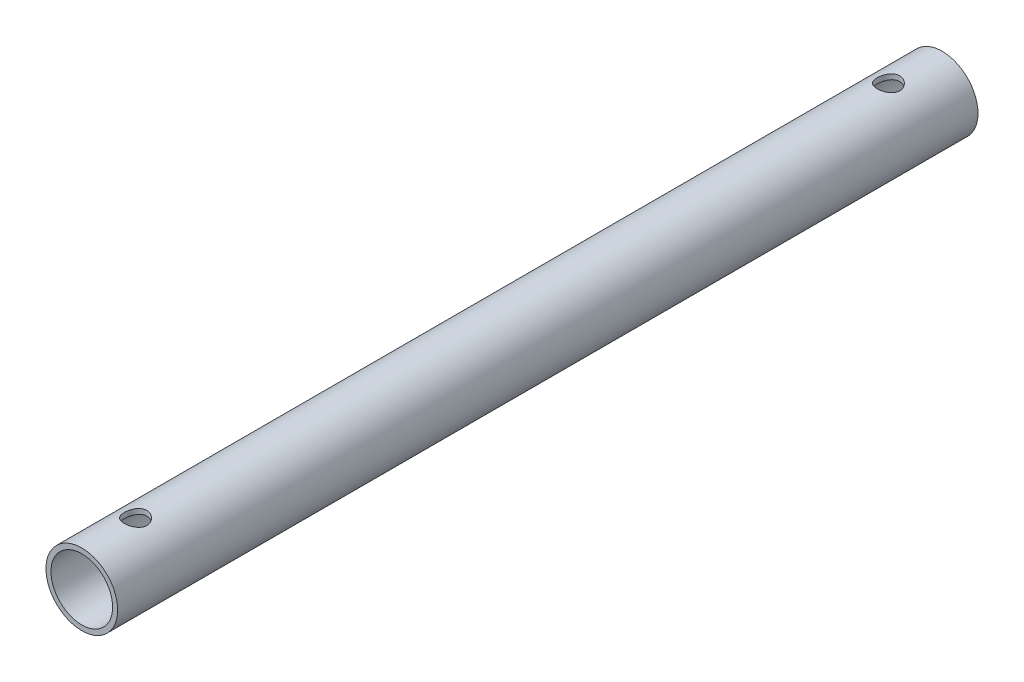
from build123d import *

# Parameters (mm, degrees)
SKETCH1_R               = 6.35
SKETCH1_R_2             = 5.461
EXTRUDE1_DEPTH          = 152.4
SKETCH2_R               = 2
CUT_EXTRUDE1_DEPTH      = 38.1
CUT_EXTRUDE1_DEPTH_BACK = 38.1


with BuildPart() as part:
    # Sketch1 → Extrude1 (new body)
    with BuildSketch(Plane.XY):
        Circle(SKETCH1_R)
        Circle(SKETCH1_R_2, mode=Mode.SUBTRACT)
    extrude(amount=EXTRUDE1_DEPTH)

    # Sketch2 → Cut-Extrude1 (cut, two sides)
    with BuildSketch(Plane(origin=(0, 0, 0), x_dir=(1, 0, 0), z_dir=(0, 1, 0))) as cut_extrude1_sk:
        with Locations(Location((0, -9.525, 0), (0, 0, 270))):  # turned: the seam where the file's is
            Circle(SKETCH2_R)
        with Locations(Location((0, -142.875, 0), (0, 0, 270))):  # turned: the seam where the file's is
            Circle(SKETCH2_R)
    extrude(amount=CUT_EXTRUDE1_DEPTH, mode=Mode.SUBTRACT)
    extrude(cut_extrude1_sk.sketch, amount=-CUT_EXTRUDE1_DEPTH_BACK, mode=Mode.SUBTRACT)


solid = part.part
